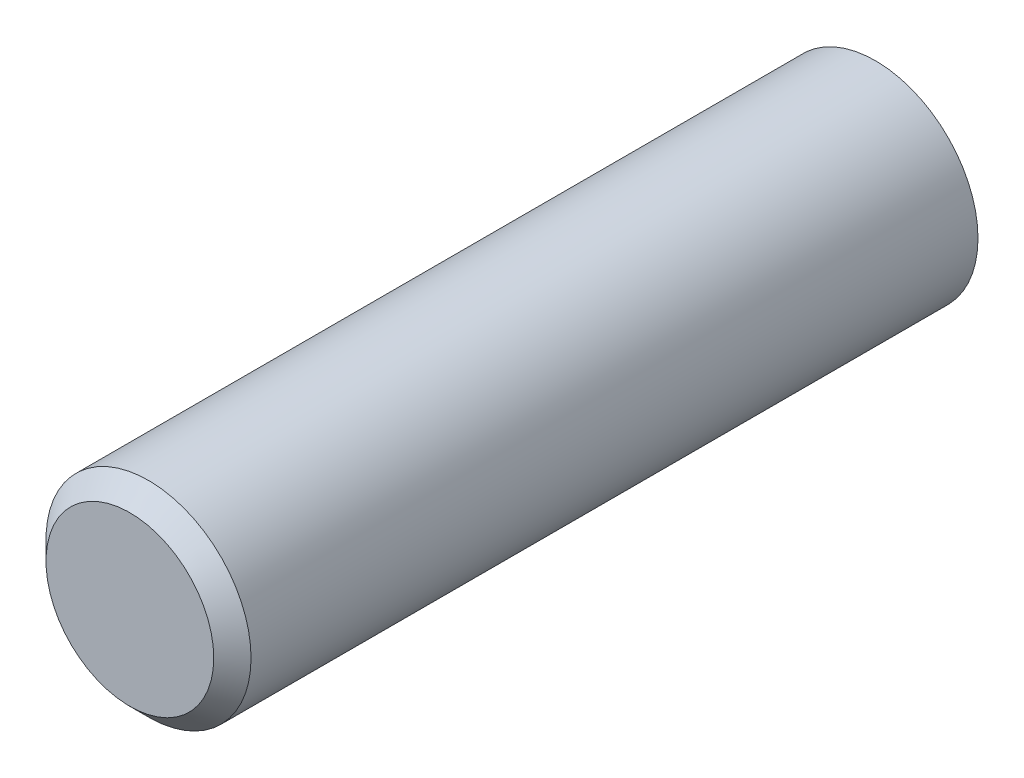
from build123d import *

# Parameters (mm, degrees)
SKETCH1_R           = 5.5
SKETCH1_R_2         = 4.7
BOSS_EXTRUDE1_DEPTH = 40
SKETCH2_R           = 5.5
BOSS_EXTRUDE2_DEPTH = 2
CHAMFER1_SIZE       = 1


with BuildPart() as part:
    # Sketch1 → Boss-Extrude1 (new body)
    with BuildSketch(Plane.XY):
        Circle(SKETCH1_R)
        Circle(SKETCH1_R_2, mode=Mode.SUBTRACT)
    extrude(amount=BOSS_EXTRUDE1_DEPTH)

    # Sketch2 → Boss-Extrude2 (add)
    with BuildSketch(Plane.XY.offset(40)):
        Circle(SKETCH2_R)
    extrude(amount=-BOSS_EXTRUDE2_DEPTH)

    # Chamfer1
    chamfer1_edges = [part.edges().sort_by_distance(p)[0] for p in [
        (-5.5, 0, 40),
    ]]
    chamfer(chamfer1_edges, length=CHAMFER1_SIZE)


solid = part.part
